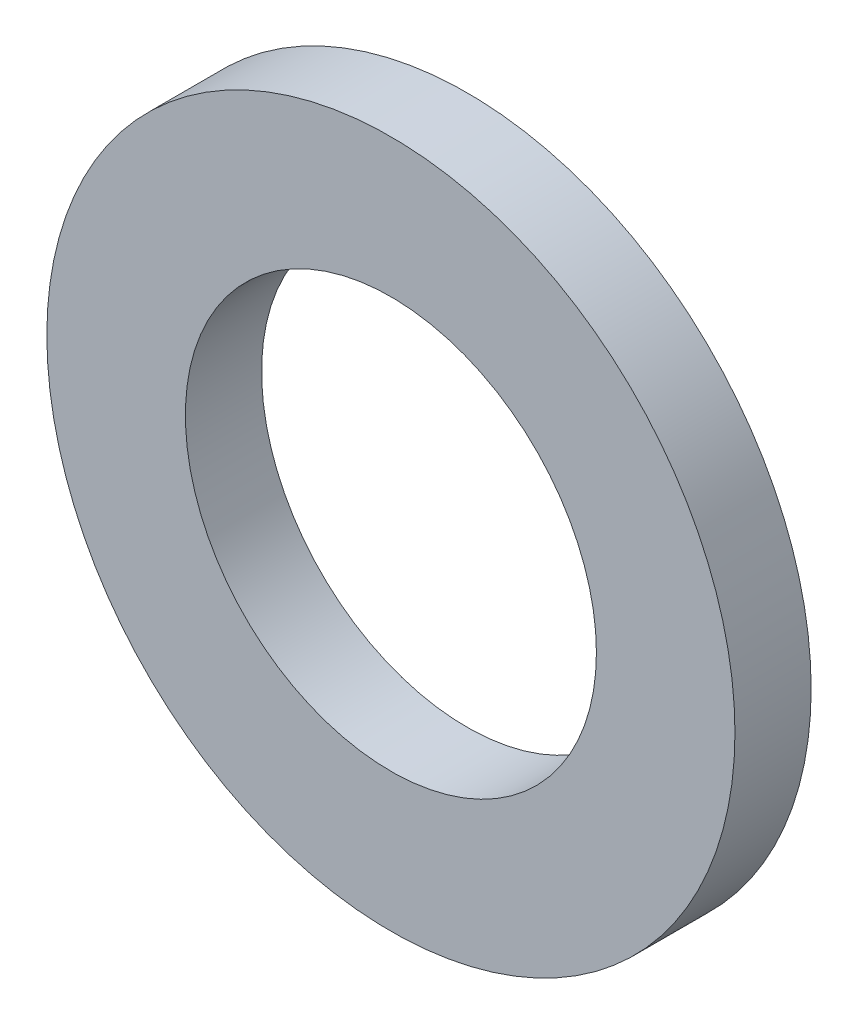
from build123d import *

# Parameters (mm, degrees)
SKETCH3_R           = 1.8923
SKETCH3_R_2         = 1.1303
BOSS_EXTRUDE1_DEPTH = 0.20955


with BuildPart() as part:
    # Sketch3 → Boss-Extrude1 (new, symmetric)
    with BuildSketch(Plane.XY):
        Circle(SKETCH3_R)
        Circle(SKETCH3_R_2, mode=Mode.SUBTRACT)
    extrude(amount=BOSS_EXTRUDE1_DEPTH, both=True)


solid = part.part
